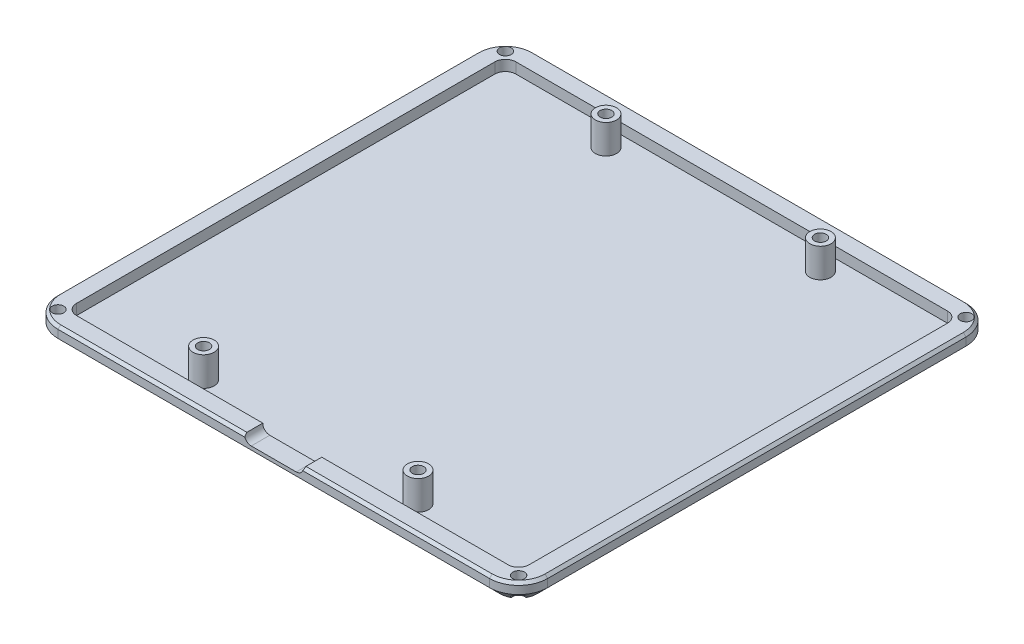
from build123d import *

# Parameters (mm, degrees)
BOSS_EXTRUDE1_DEPTH = 4
CUT_EXTRUDE1_DEPTH  = 2
CUT_EXTRUDE2_DEPTH  = 3.5
CHAMFER2_SIZE       = 2
CHAMFER3_SIZE       = 0.5
SKETCH4_R           = 2
SKETCH4_R_2         = 1.1
BOSS_EXTRUDE2_DEPTH = 5.5
SKETCH5_R           = 1.1
CUT_EXTRUDE3_DEPTH  = 4


with BuildPart() as part:
    # Sketch1 → Boss-Extrude1 (new body)
    with BuildSketch(Plane(origin=(0, 0, 0), x_dir=(1, 0, 0), z_dir=(0, 1, 0))):
        with BuildLine():
            Line((40.75, 45.000726786), (-40.75, 45.000726786))
            ThreePointArc((-40.75, 45.000726786), (-44.639601212, 43.389601212), (-46.250726786, 39.5))
            Line((-46.250726786, 39.5), (-46.250726786, -39.5))
            ThreePointArc((-46.250726786, -39.5), (-44.639601212, -43.389601212), (-40.75, -45.000726786))
            Line((-40.75, -45.000726786), (40.75, -45.000726786))
            ThreePointArc((40.75, -45.000726786), (44.639601212, -43.389601212), (46.250726786, -39.5))
            Line((46.250726786, -39.5), (46.250726786, 39.5))
            ThreePointArc((46.250726786, 39.5), (44.639601212, 43.389601212), (40.75, 45.000726786))
        make_face()
    extrude(amount=BOSS_EXTRUDE1_DEPTH)

    # Sketch2 → Cut-Extrude1 (cut)
    with BuildSketch(Plane(origin=(0, 4, 0), x_dir=(1, 0, 0), z_dir=(0, 1, 0))):
        with BuildLine():
            Line((-42.750726786, 39.5), (-42.750726786, -39.5))
            ThreePointArc((-42.750726786, -39.5), (-42.164727477, -40.914727477), (-40.75, -41.500726786))
            Line((-40.75, -41.500726786), (40.75, -41.500726786))
            ThreePointArc((40.75, -41.500726786), (42.164727477, -40.914727477), (42.750726786, -39.5))
            Line((42.750726786, -39.5), (42.750726786, 39.5))
            ThreePointArc((42.750726786, 39.5), (42.164727477, 40.914727477), (40.75, 41.500726786))
            Line((40.75, 41.500726786), (-40.75, 41.500726786))
            ThreePointArc((-40.75, 41.500726786), (-42.164727477, 40.914727477), (-42.750726786, 39.5))
        make_face()
    extrude(amount=-CUT_EXTRUDE1_DEPTH, mode=Mode.SUBTRACT)

    # Sketch3 → Cut-Extrude2 (cut)
    with BuildSketch(Plane.XY.offset(45.000726786)):
        with BuildLine():
            Line((-4.25, 5.325), (4.25, 5.325))
            ThreePointArc((4.25, 5.325), (5.575, 4), (4.25, 2.675))
            Line((4.25, 2.675), (-4.25, 2.675))
            ThreePointArc((-4.25, 2.675), (-5.575, 4), (-4.25, 5.325))
        make_face()
    extrude(amount=-CUT_EXTRUDE2_DEPTH, mode=Mode.SUBTRACT)

    # Chamfer2
    chamfer2_edges = [part.edges().sort_by_distance(p)[0] for p in [
        (44.639601212, 0, -43.389601212),
        (46.250726786, 0, 0),
        (44.639601212, 0, 43.389601212),
        (0, 0, 45.000726786),
        (-44.639601212, 0, 43.389601212),
        (-46.250726786, 0, 0),
        (-44.639601212, 0, -43.389601212),
        (0, 0, -45.000726786),
    ]]
    chamfer(chamfer2_edges, length=CHAMFER2_SIZE)

    # Chamfer3
    chamfer3_edges = [part.edges().sort_by_distance(p)[0] for p in [
        (46.250726786, 4, 0),
        (44.639601212, 4, -43.389601212),
        (0, 4, -45.000726786),
        (-44.639601212, 4, -43.389601212),
        (-46.250726786, 4, 0),
        (-44.639601212, 4, 43.389601212),
        (-23.1625, 4, 45.000726786),
        (23.1625, 4, 45.000726786),
        (44.639601212, 4, 43.389601212),
    ]]
    chamfer(chamfer3_edges, length=CHAMFER3_SIZE)

    # Sketch4 → Boss-Extrude2 (add)
    with BuildSketch(Plane(origin=(0, 2, 0), x_dir=(1, 0, 0), z_dir=(0, 1, 0))):
        with Locations((-20.250726786, -38.000726786)):
            Circle(SKETCH4_R)
        with Locations((-20.250726786, -38.000726786)):
            Circle(SKETCH4_R_2, mode=Mode.SUBTRACT)
        with Locations((20.250726786, -38.000726786)):
            Circle(SKETCH4_R)
        with Locations((20.250726786, -38.000726786)):
            Circle(SKETCH4_R_2, mode=Mode.SUBTRACT)
        with Locations((20.250726786, 38.000726786)):
            Circle(SKETCH4_R)
        with Locations((20.250726786, 38.000726786)):
            Circle(SKETCH4_R_2, mode=Mode.SUBTRACT)
        with Locations((-20.250726786, 38.000726786)):
            Circle(SKETCH4_R)
        with Locations((-20.250726786, 38.000726786)):
            Circle(SKETCH4_R_2, mode=Mode.SUBTRACT)
    extrude(amount=BOSS_EXTRUDE2_DEPTH)

    # Sketch5 → Cut-Extrude3 (cut)
    with BuildSketch(Plane.XZ):
        with Locations((-43.500363393, 42.250363393)):
            Circle(SKETCH5_R)
        with Locations((43.500363393, 42.250363393)):
            Circle(SKETCH5_R)
        with Locations((43.500363393, -42.250363393)):
            Circle(SKETCH5_R)
        with Locations((-43.500363393, -42.250363393)):
            Circle(SKETCH5_R)
    extrude(amount=-CUT_EXTRUDE3_DEPTH, mode=Mode.SUBTRACT)


solid = part.part
